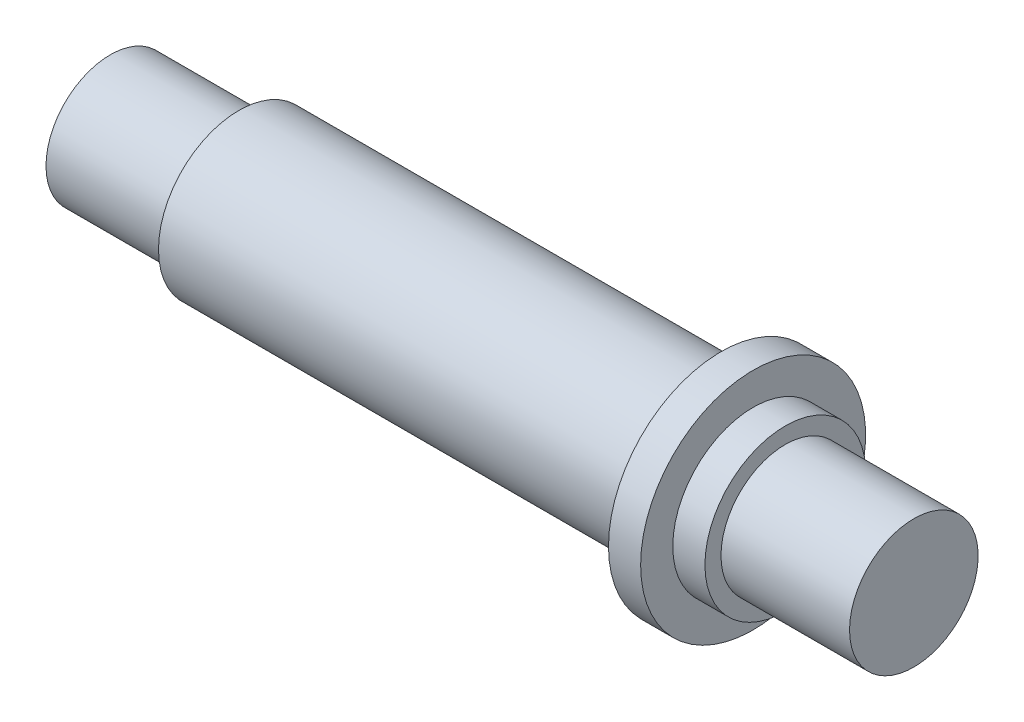
from build123d import *


with BuildPart() as part:
    # 草图1 → 旋转1 (revolve)
    with BuildSketch(Plane.XY):
        Polygon((-45.15451692, 0), (-45.15451692, 2), (-41.15451692, 2), (-41.15451692, 2.5), (-26.15451692, 2.5), (-26.15451692, 3.5), (-25.15451692, 3.5), (-25.15451692, 2.5), (-24.15451692, 2.5), (-24.15451692, 2), (-20.15451692, 2), (-20.15451692, 0), align=None)
    revolve(axis=Axis((-56.479220812, 0, 0), (1, 0, 0)))


solid = part.part
